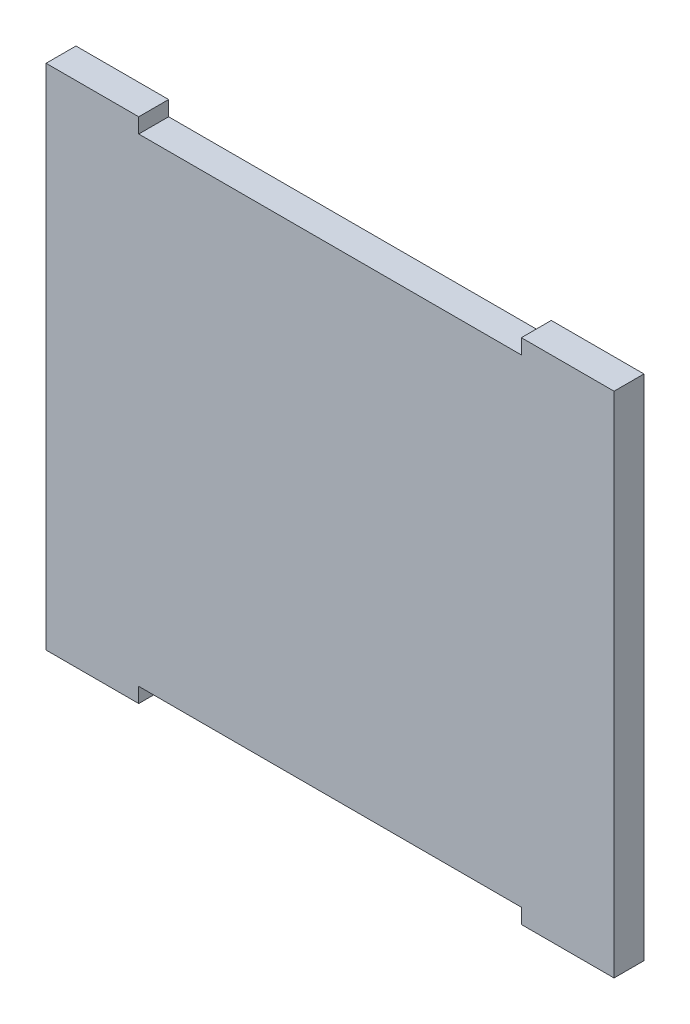
from build123d import *

# Parameters (mm, degrees)
EXTRUDE_1_DEPTH = 10


with BuildPart() as part:
    # 草图1 → 凸台-拉伸1 (new body)
    with BuildSketch(Plane.XY):
        Polygon((1270.864081606, 373.563048005), (1239.864081606, 373.563048005), (1239.864081606, 543.563048005), (1270.864081606, 543.563048005), (1270.864081606, 538.563048005), (1398.864081606, 538.563048005), (1398.864081606, 543.563048005), (1429.864081606, 543.563048005), (1429.864081606, 373.563048005), (1398.864081606, 373.563048005), (1398.864081606, 378.563048005), (1270.864081606, 378.563048005), align=None)
    extrude(amount=EXTRUDE_1_DEPTH)


solid = part.part
